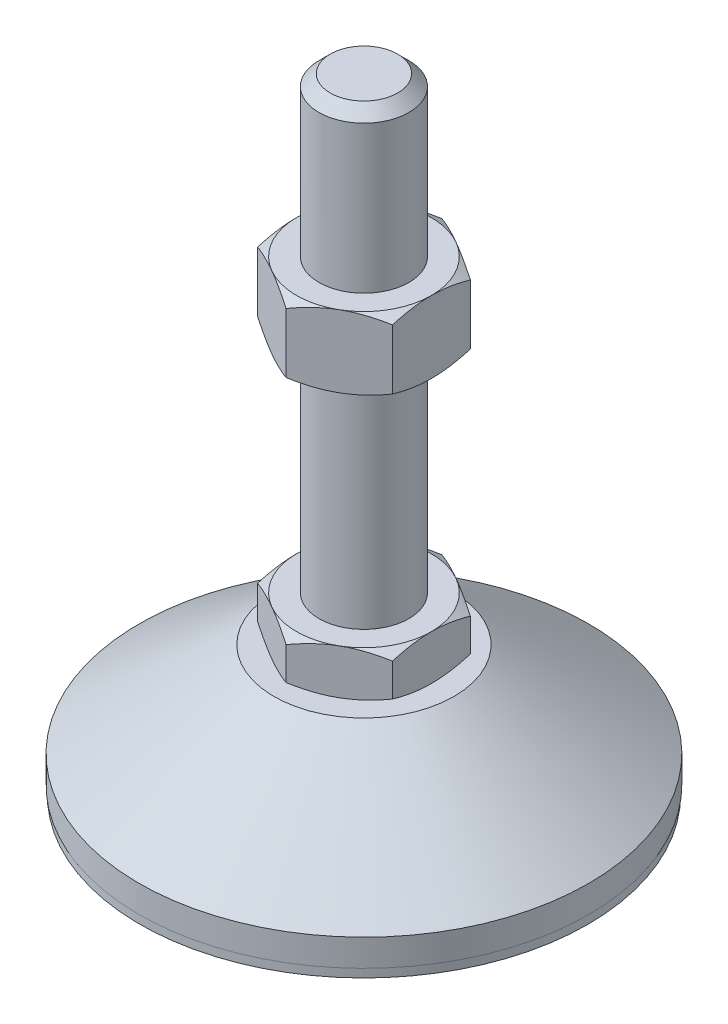
from build123d import *

# Parameters (mm, degrees)
EXTRUDE_1_DEPTH = 10
EXTRUDE_2_DEPTH = 16


with BuildPart() as part:
    # Эскиз1 → Повернуть1 (revolve)
    with BuildSketch(Plane.XY, mode=Mode.PRIVATE) as revolve_1_sk:
        Polygon((0, 0), (-49.8, 0), (-49.8, 2), (-50, 2), (-50, 8), (-20, 29), (-10, 29), (-10, 39), (-10, 136.5), (-7.5, 139), (0, 139), align=None)
    revolve(revolve_1_sk.sketch.rotate(Axis((0, 0, 0), (0, 1, 0)), 180), axis=Axis((0, 0, 0), (0, 1, 0)))  # turned: the seam where the file's is

    # Эскиз2 → Бобышка-Вытянуть1 (add)
    with BuildSketch(Plane(origin=(0, 29, 0), x_dir=(1, 0, 0), z_dir=(0, 1, 0))):
        Polygon((0, 17.320508076), (-15, 8.660254038), (-15, -8.660254038), (0, -17.320508076), (15, -8.660254038), (15, 8.660254038), align=None)
    extrude(amount=EXTRUDE_1_DEPTH)

    # Эскиз3 → Бобышка-Вытянуть2 (add)
    with BuildSketch(Plane(origin=(0, 87.75, 0), x_dir=(1, 0, 0), z_dir=(0, 1, 0))):
        Polygon((15, 8.660254038), (0, 17.320508076), (-15, 8.660254038), (-15, -8.660254038), (0, -17.320508076), (15, -8.660254038), align=None)
    extrude(amount=EXTRUDE_2_DEPTH)

    # Эскиз4 → Вырез-Повернуть2 (revolve, cut)
    with BuildSketch(Plane.XY, mode=Mode.PRIVATE) as cut_revolve_2_sk:
        Polygon((-28.856406461, 103.75), (-15, 103.75), (-28.856406461, 95.75), align=None)
        Polygon((-28.856406461, 87.75), (-28.856406461, 95.75), (-15, 87.75), align=None)
        Polygon((-23.660254038, 39), (-23.660254038, 34), (-15, 39), align=None)
        Polygon((-23.660254038, 34), (-23.660254038, 29), (-15, 29), align=None)
    revolve(cut_revolve_2_sk.sketch.rotate(Axis((0, 139, 0), (0, -1, 0)), 180), axis=Axis((0, 139, 0), (0, -1, 0)), mode=Mode.SUBTRACT)  # turned: the seam where the file's is


solid = part.part
